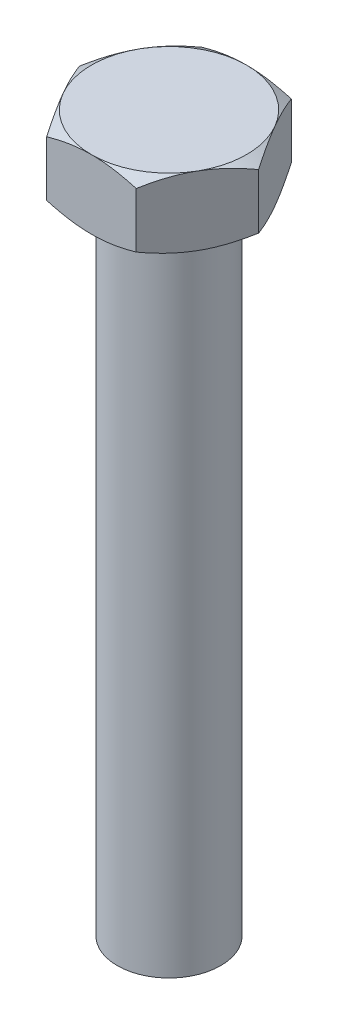
from build123d import *

# Parameters (mm, degrees)
BOSS_EXTRUDE1_DEPTH = 8
SKETCH3_R           = 6
BOSS_EXTRUDE2_DEPTH = 75


with BuildPart() as part:
    # Sketch1 → Boss-Extrude1 (new body)
    with BuildSketch(Plane(origin=(0, 0, 0), x_dir=(1, 0, 0), z_dir=(0, 1, 0))):
        Polygon((5.196152423, 9), (-5.196152423, 9), (-10.392304845, 0), (-5.196152423, -9), (5.196152423, -9), (10.392304845, 0), align=None)
    extrude(amount=BOSS_EXTRUDE1_DEPTH)

    # Sketch2 → Cut-Revolve1 (revolve, cut)
    with BuildSketch(Plane.XY):
        Polygon((-10.392304845, 0), (-9, 0), (-10.392304845, 0.803847577), align=None)
        Polygon((-10.392304845, 8), (-9, 8), (-10.392304845, 7.196152423), align=None)
    revolve(axis=Axis((0, 55, 0), (0, -1, 0)), mode=Mode.SUBTRACT)

    # Sketch3 → Boss-Extrude2 (add)
    with BuildSketch(Plane.XZ):
        Circle(SKETCH3_R)
    extrude(amount=BOSS_EXTRUDE2_DEPTH)


solid = part.part
